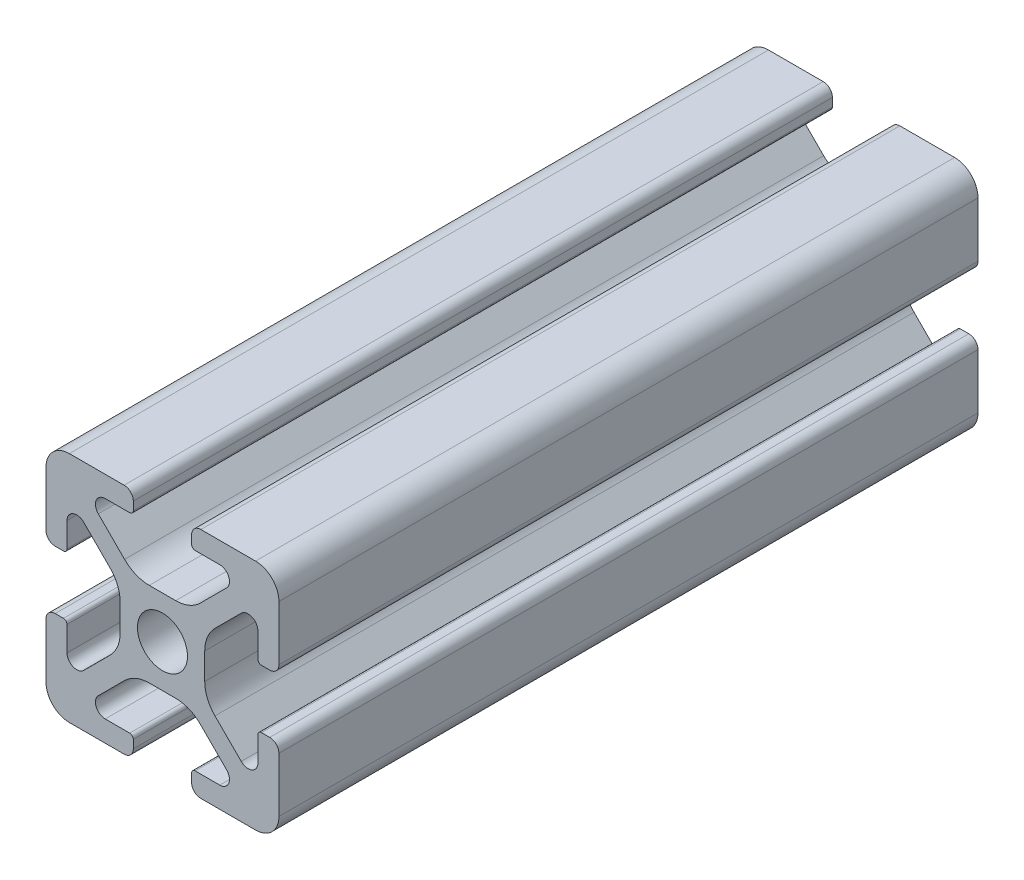
from build123d import *

# Parameters (mm, degrees)
SKETCH1_R           = 2.1463
BOSS_EXTRUDE1_DEPTH = 30


with BuildPart() as part:
    # Sketch1 → Boss-Extrude1 (new body, symmetric)
    with BuildSketch(Plane.XY):
        with BuildLine():
            Line((-9.9949, 7.9883), (-9.9949, 3.2893))
            ThreePointArc((-9.9949, 3.2893), (-9.76427588, 2.73252412), (-9.2075, 2.5019))
            Line((-9.2075, 2.5019), (-8.4963, 2.5019))
            ThreePointArc((-8.4963, 2.5019), (-8.280773853, 2.591173853), (-8.1915, 2.8067))
            Line((-8.1915, 2.8067), (-8.1915, 4.9149))
            ThreePointArc((-8.1915, 4.9149), (-7.674065253, 5.689295824), (-6.760603096, 5.507596904))
            Line((-6.760603096, 5.507596904), (-4.505765747, 3.252759555))
            ThreePointArc((-4.505765747, 3.252759555), (-3.856054457, 2.280397894), (-3.627906192, 1.133419111))
            Line((-3.627906192, 1.133419111), (-3.627906192, -1.133419111))
            ThreePointArc((-3.627906192, -1.133419111), (-3.856054457, -2.280397894), (-4.505765747, -3.252759555))
            Line((-4.505765747, -3.252759555), (-6.760603096, -5.507596904))
            ThreePointArc((-6.760603096, -5.507596904), (-7.674065253, -5.689295824), (-8.1915, -4.9149))
            Line((-8.1915, -4.9149), (-8.1915, -2.8067))
            ThreePointArc((-8.1915, -2.8067), (-8.280773853, -2.591173853), (-8.4963, -2.5019))
            Line((-8.4963, -2.5019), (-9.2075, -2.5019))
            ThreePointArc((-9.2075, -2.5019), (-9.76427588, -2.73252412), (-9.9949, -3.2893))
            Line((-9.9949, -3.2893), (-9.9949, -7.9883))
            ThreePointArc((-9.9949, -7.9883), (-9.407180467, -9.407180467), (-7.9883, -9.9949))
            Line((-7.9883, -9.9949), (-3.2893, -9.9949))
            ThreePointArc((-3.2893, -9.9949), (-2.73252412, -9.76427588), (-2.5019, -9.2075))
            Line((-2.5019, -9.2075), (-2.5019, -8.4963))
            ThreePointArc((-2.5019, -8.4963), (-2.591173853, -8.280773853), (-2.8067, -8.1915))
            Line((-2.8067, -8.1915), (-4.9149, -8.1915))
            ThreePointArc((-4.9149, -8.1915), (-5.689295824, -7.674065253), (-5.507596904, -6.760603096))
            Line((-5.507596904, -6.760603096), (-3.252759555, -4.505765747))
            ThreePointArc((-3.252759555, -4.505765747), (-2.280397894, -3.856054457), (-1.133419111, -3.627906192))
            Line((-1.133419111, -3.627906192), (1.133419111, -3.627906192))
            ThreePointArc((1.133419111, -3.627906192), (2.280397894, -3.856054457), (3.252759555, -4.505765747))
            Line((3.252759555, -4.505765747), (5.507596904, -6.760603096))
            ThreePointArc((5.507596904, -6.760603096), (5.689295824, -7.674065253), (4.9149, -8.1915))
            Line((4.9149, -8.1915), (2.8067, -8.1915))
            ThreePointArc((2.8067, -8.1915), (2.591173853, -8.280773853), (2.5019, -8.4963))
            Line((2.5019, -8.4963), (2.5019, -9.2075))
            ThreePointArc((2.5019, -9.2075), (2.73252412, -9.76427588), (3.2893, -9.9949))
            Line((3.2893, -9.9949), (7.9883, -9.9949))
            ThreePointArc((7.9883, -9.9949), (9.407180467, -9.407180467), (9.9949, -7.9883))
            Line((9.9949, -7.9883), (9.9949, -3.2893))
            ThreePointArc((9.9949, -3.2893), (9.76427588, -2.73252412), (9.2075, -2.5019))
            Line((9.2075, -2.5019), (8.4963, -2.5019))
            ThreePointArc((8.4963, -2.5019), (8.280773853, -2.591173853), (8.1915, -2.8067))
            Line((8.1915, -2.8067), (8.1915, -4.9149))
            ThreePointArc((8.1915, -4.9149), (7.674065253, -5.689295824), (6.760603096, -5.507596904))
            Line((6.760603096, -5.507596904), (4.505765747, -3.252759555))
            ThreePointArc((4.505765747, -3.252759555), (3.856054457, -2.280397894), (3.627906192, -1.133419111))
            Line((3.627906192, -1.133419111), (3.627906192, 1.133419111))
            ThreePointArc((3.627906192, 1.133419111), (3.856054457, 2.280397894), (4.505765747, 3.252759555))
            Line((4.505765747, 3.252759555), (6.760603096, 5.507596904))
            ThreePointArc((6.760603096, 5.507596904), (7.674065253, 5.689295824), (8.1915, 4.9149))
            Line((8.1915, 4.9149), (8.1915, 2.8067))
            ThreePointArc((8.1915, 2.8067), (8.280773853, 2.591173853), (8.4963, 2.5019))
            Line((8.4963, 2.5019), (9.2075, 2.5019))
            ThreePointArc((9.2075, 2.5019), (9.76427588, 2.73252412), (9.9949, 3.2893))
            Line((9.9949, 3.2893), (9.9949, 7.9883))
            ThreePointArc((9.9949, 7.9883), (9.407180467, 9.407180467), (7.9883, 9.9949))
            Line((7.9883, 9.9949), (3.2893, 9.9949))
            ThreePointArc((3.2893, 9.9949), (2.73252412, 9.76427588), (2.5019, 9.2075))
            Line((2.5019, 9.2075), (2.5019, 8.4963))
            ThreePointArc((2.5019, 8.4963), (2.591173853, 8.280773853), (2.8067, 8.1915))
            Line((2.8067, 8.1915), (4.9149, 8.1915))
            ThreePointArc((4.9149, 8.1915), (5.689295824, 7.674065253), (5.507596904, 6.760603096))
            Line((5.507596904, 6.760603096), (3.252759555, 4.505765747))
            ThreePointArc((3.252759555, 4.505765747), (2.280397894, 3.856054457), (1.133419111, 3.627906192))
            Line((1.133419111, 3.627906192), (-1.133419111, 3.627906192))
            ThreePointArc((-1.133419111, 3.627906192), (-2.280397894, 3.856054457), (-3.252759555, 4.505765747))
            Line((-3.252759555, 4.505765747), (-5.507596904, 6.760603096))
            ThreePointArc((-5.507596904, 6.760603096), (-5.689295824, 7.674065253), (-4.9149, 8.1915))
            Line((-4.9149, 8.1915), (-2.8067, 8.1915))
            ThreePointArc((-2.8067, 8.1915), (-2.591173853, 8.280773853), (-2.5019, 8.4963))
            Line((-2.5019, 8.4963), (-2.5019, 9.2075))
            ThreePointArc((-2.5019, 9.2075), (-2.73252412, 9.76427588), (-3.2893, 9.9949))
            Line((-3.2893, 9.9949), (-7.9883, 9.9949))
            ThreePointArc((-7.9883, 9.9949), (-9.407180467, 9.407180467), (-9.9949, 7.9883))
        make_face()
        Circle(SKETCH1_R, mode=Mode.SUBTRACT)
    extrude(amount=BOSS_EXTRUDE1_DEPTH, both=True)


solid = part.part
